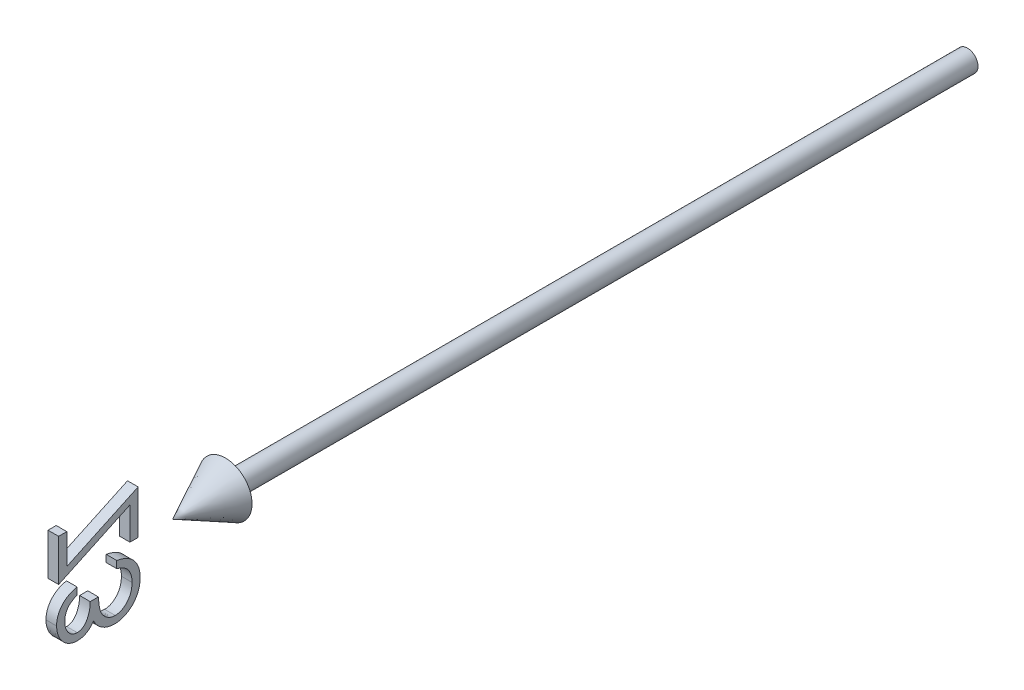
from build123d import *

# Parameters (mm, degrees)
BOSS_EXTRUDE1_DEPTH        = 1
BOSS_EXTRUDE1_DEPTH_BACK   = 1
BOSS_EXTRUDE1_2_DEPTH      = 1
BOSS_EXTRUDE1_2_DEPTH_BACK = 1


with BuildPart() as part:
    # Sketch2 → Revolve1 (revolve)
    with BuildSketch(Plane(origin=(0, 0, 0), x_dir=(1, 0, 0), z_dir=(0, 1, 0))):
        Polygon((0, -150), (5, -140), (2, -140), (2, 0), (0, 0), align=None)
    revolve(axis=Axis((0, 0, -41.949952025), (0, 0, 1)))


with BuildPart() as body_2:
    # Sketch3 → Boss-Extrude1 (new, two sides: drawn at the far end of the back side and taken through both)
    with BuildSketch(Plane(origin=(0, 0, 0), x_dir=(0, -1, 0), z_dir=(1, 0, 0)).offset(-BOSS_EXTRUDE1_DEPTH_BACK)):
        Polygon((-8.958586521, -170.961538462), (-8.958586521, -172.5), (-1.073971137, -172.5), (-7.366038444, -159.038461538), (-1.266278829, -159.038461538), (-1.266278829, -157.5), (-9.535509598, -157.5), (-3.243442291, -170.961538462), align=None)
    extrude(amount=BOSS_EXTRUDE1_DEPTH + BOSS_EXTRUDE1_DEPTH_BACK)


with BuildPart() as body_3:
    # Sketch3 → Boss-Extrude1 2 (new, two sides: drawn at the far end of the back side and taken through both)
    with BuildSketch(Plane(origin=(0, 0, 0), x_dir=(0, -1, 0), z_dir=(1, 0, 0)).offset(-BOSS_EXTRUDE1_2_DEPTH_BACK)):
        with BuildLine():
            Line((2.387567325, -169.038461538), (1.041413479, -169.038461538))
            add(Edge.make_bspline(
                [(1.041413479, -169.038461538), (1.077882982, -169.189457898), (1.149177877, -169.484643431), (1.297881763, -169.906388835), (1.459878571, -170.305489641), (1.654403305, -170.674472814), (1.86658368, -171.020753826), (2.109681058, -171.336478645), (2.372479869, -171.629677068), (2.663158223, -171.889876658), (2.967995345, -172.125495497), (3.291286572, -172.3263886), (3.626527545, -172.499206398), (3.976040972, -172.641578821), (4.340867422, -172.748831065), (4.717708665, -172.826645946), (5.107552237, -172.877179293), (5.372184768, -172.882111134), (5.506557709, -172.884615385)],
                knots=[0, 0, 0, 0, 1.162005537, 2.271625781, 3.343758855, 4.383309926, 5.390229558, 6.379919256, 7.361854164, 8.333198761, 9.295911338, 10.242430842, 11.177959212, 12.116337295, 13.062827104, 14.020064771, 14.994644689, 16, 16, 16, 16], degree=3))
            add(Edge.make_bspline(
                [(5.506557709, -172.884615385), (5.70234089, -172.878704398), (6.089636651, -172.86701136), (6.658621138, -172.760235204), (7.207307505, -172.591270351), (7.729689996, -172.35781152), (8.21491185, -172.069865892), (8.646638365, -171.727159877), (9.019017697, -171.336305728), (9.331422172, -170.904594738), (9.576029311, -170.443213983), (9.756399483, -169.968356167), (9.866206688, -169.481147718), (9.880437645, -169.15218795), (9.887567325, -168.987379808)],
                knots=[0, 0, 0, 0, 1.083050992, 2.142477498, 3.193116406, 4.255571735, 5.30263384, 6.308962982, 7.297363603, 8.282367274, 9.249857812, 10.179914175, 11.08814088, 12, 12, 12, 12], degree=3))
            add(Edge.make_bspline(
                [(9.887567325, -168.987379808), (9.882580506, -168.828779259), (9.872822076, -168.518422597), (9.789963337, -168.065330466), (9.650522211, -167.638295037), (9.457366086, -167.235518627), (9.20733087, -166.859555028), (8.904447884, -166.509558353), (8.546579333, -166.183976247), (8.275383884, -165.99746422), (8.13576444, -165.901442308)],
                knots=[0, 0, 0, 0, 1.024540389, 2.004866551, 2.965041327, 3.920577974, 4.882998113, 5.874504559, 6.905732034, 8, 8, 8, 8], degree=3))
            add(Edge.make_bspline(
                [(8.13576444, -165.901442308), (8.295532489, -165.824672319), (8.612592213, -165.672322261), (9.040398309, -165.368793148), (9.434677535, -165.026944029), (9.651975175, -164.757191084), (9.761365402, -164.621394231)],
                knots=[0, 0, 0, 0, 1.015663554, 2.015584519, 3.001021554, 4, 4, 4, 4], degree=3))
            add(Edge.make_bspline(
                [(9.761365402, -164.621394231), (9.833571964, -164.522585827), (9.976802655, -164.326587074), (10.153097142, -164.011277108), (10.314859216, -163.693516116), (10.43391142, -163.360810145), (10.536648754, -163.023846298), (10.604246499, -162.675408835), (10.647641548, -162.318808204), (10.653735099, -162.077450896), (10.656798094, -161.956129808)],
                knots=[0, 0, 0, 0, 1.02516404, 2.033540309, 3.025129118, 4.011046665, 4.991655828, 5.976607087, 6.982917762, 8, 8, 8, 8], degree=3))
            add(Edge.make_bspline(
                [(10.656798094, -161.956129808), (10.649089282, -161.746097574), (10.633707934, -161.327021522), (10.496818218, -160.707702714), (10.283287572, -160.103433888), (9.98569722, -159.522784723), (9.615837461, -158.981167895), (9.178243054, -158.495173184), (8.672448055, -158.081236409), (8.113179027, -157.732313488), (7.504922756, -157.455796007), (6.856929846, -157.256542751), (6.173036865, -157.137018745), (5.705353383, -157.122678096), (5.467495209, -157.115384615)],
                knots=[0, 0, 0, 0, 0.955619592, 1.906742024, 2.874954321, 3.868585453, 4.869520953, 5.854611167, 6.836527075, 7.836578462, 8.849204403, 9.870874567, 10.917152508, 12, 12, 12, 12], degree=3))
            add(Edge.make_bspline(
                [(5.467495209, -157.115384615), (5.307136874, -157.119137984), (4.991605144, -157.12652336), (4.527560673, -157.176112305), (4.085547169, -157.26914479), (3.661272508, -157.386146016), (3.261140023, -157.547913319), (2.879394184, -157.740769913), (2.517708313, -157.969661352), (2.178230348, -158.234972564), (1.861322974, -158.531948792), (1.575059945, -158.865523642), (1.316274062, -159.22947145), (1.086609618, -159.627065987), (0.885100046, -160.057193647), (0.716081847, -160.52157803), (0.568508081, -161.016619024), (0.4997621, -161.361508239), (0.464490402, -161.538461538)],
                knots=[0, 0, 0, 0, 1.048603596, 2.063302207, 3.045874044, 3.999447474, 4.937100059, 5.862643889, 6.7929026, 7.7308982, 8.676022965, 9.627908155, 10.600123445, 11.591992905, 12.626222643, 13.701663232, 14.820785756, 16, 16, 16, 16], degree=3))
            Line((0.464490402, -161.538461538), (1.810644248, -161.538461538))
            add(Edge.make_bspline(
                [(1.810644248, -161.538461538), (1.845715497, -161.422965767), (1.913932123, -161.19831646), (2.030050543, -160.875000865), (2.162343137, -160.578609208), (2.304262674, -160.306967257), (2.453313157, -160.057399817), (2.620091408, -159.836506093), (2.792244887, -159.634583798), (2.922013544, -159.520821175), (2.985524056, -159.465144231)],
                knots=[0, 0, 0, 0, 1.198163088, 2.33053128, 3.407730985, 4.417276592, 5.372219308, 6.28897303, 7.162600585, 8, 8, 8, 8], degree=3))
            add(Edge.make_bspline(
                [(2.985524056, -159.465144231), (3.069518764, -159.400420928), (3.237248909, -159.271174108), (3.510400544, -159.105766423), (3.79867748, -158.964181399), (4.104483743, -158.849095157), (4.427860356, -158.762707273), (4.767495568, -158.70052934), (5.123946634, -158.659482243), (5.367217522, -158.655752252), (5.491533671, -158.653846154)],
                knots=[0, 0, 0, 0, 0.946083416, 1.889246487, 2.84504177, 3.809995578, 4.801312957, 5.829064617, 6.89060985, 8, 8, 8, 8], degree=3))
            add(Edge.make_bspline(
                [(5.491533671, -158.653846154), (5.631907725, -158.656481455), (5.906397071, -158.661634559), (6.306891349, -158.709161849), (6.68801812, -158.7780779), (7.045887986, -158.885876004), (7.385370678, -159.015197637), (7.698887961, -159.18450339), (7.995656856, -159.375706866), (8.266983406, -159.598113283), (8.511597558, -159.838510547), (8.722971211, -160.093550619), (8.90604497, -160.355325599), (9.05320572, -160.629942168), (9.16961678, -160.914706557), (9.248816734, -161.210684643), (9.303898319, -161.515384104), (9.308383304, -161.722508678), (9.310644248, -161.826923077)],
                knots=[0, 0, 0, 0, 1.216990249, 2.379719373, 3.493992396, 4.571561497, 5.616923107, 6.638958652, 7.655775068, 8.674704564, 9.676001865, 10.625896028, 11.54399481, 12.441854662, 13.322657739, 14.20572845, 15.095482574, 16, 16, 16, 16], degree=3))
            add(Edge.make_bspline(
                [(9.310644248, -161.826923077), (9.304072128, -161.966677177), (9.290960591, -162.245489979), (9.191271648, -162.65583968), (9.025831107, -163.051362848), (8.798724763, -163.426879766), (8.51564065, -163.770839724), (8.189960141, -164.078720963), (7.814734235, -164.335079469), (7.467421351, -164.511707124), (7.158983186, -164.629387155), (6.895561346, -164.711908051), (6.600388976, -164.777872173), (6.277012802, -164.841679918), (5.924067986, -164.895172125), (5.541236851, -164.939973992), (5.128365289, -164.975766197), (4.842546582, -164.991758771), (4.695259633, -165)],
                knots=[0, 0, 0, 0, 1.070440979, 2.135555593, 3.216243406, 4.345886539, 5.486149072, 6.621334998, 7.769144672, 8.957074012, 9.598644492, 10.297969361, 11.070758978, 11.915404831, 12.824182859, 13.805940418, 14.869366021, 16, 16, 16, 16], degree=3))
            Line((4.695259633, -165), (4.695259633, -166.538461538))
            add(Edge.make_bspline(
                [(4.695259633, -166.538461538), (4.880763881, -166.542078261), (5.243994071, -166.549160054), (5.776072015, -166.617174729), (6.283308569, -166.727572157), (6.758074146, -166.881701308), (7.18856769, -167.069341367), (7.565618942, -167.279426553), (7.875663405, -167.521793169), (8.124254, -167.78498421), (8.308636345, -168.069055173), (8.444736501, -168.363785951), (8.525236874, -168.674659554), (8.536002291, -168.886772035), (8.541413479, -168.993389423)],
                knots=[0, 0, 0, 0, 1.321816535, 2.58820849, 3.816448615, 5.017641336, 6.139869627, 7.160068286, 8.085608132, 8.934319198, 9.728416342, 10.48890201, 11.240453369, 12, 12, 12, 12], degree=3))
            add(Edge.make_bspline(
                [(8.541413479, -168.993389423), (8.539676508, -169.071735839), (8.536220886, -169.227602318), (8.490900512, -169.456030872), (8.425944751, -169.677479423), (8.33157719, -169.889360491), (8.209531247, -170.092347627), (8.061873825, -170.287182207), (7.888230891, -170.475724728), (7.689730048, -170.653816891), (7.468198023, -170.814102991), (7.232526248, -170.956995816), (6.98179593, -171.077148339), (6.717641012, -171.176746622), (6.438633609, -171.251536628), (6.146241516, -171.305271612), (5.839863659, -171.338858792), (5.630842238, -171.343695244), (5.524586556, -171.346153846)],
                knots=[0, 0, 0, 0, 0.884246871, 1.759167212, 2.622361933, 3.489113179, 4.372562419, 5.294145153, 6.247651513, 7.265905295, 8.30305477, 9.334068495, 10.37719476, 11.441246459, 12.52060732, 13.637552802, 14.799054011, 16, 16, 16, 16], degree=3))
            add(Edge.make_bspline(
                [(5.524586556, -171.346153846), (5.353788049, -171.340202433), (5.02017884, -171.328577938), (4.539336404, -171.226403869), (4.092789714, -171.06451959), (3.752611213, -170.869044803), (3.500985165, -170.676749979), (3.317728145, -170.511318743), (3.141049606, -170.323753604), (2.977882574, -170.108909862), (2.818449734, -169.874175124), (2.664273432, -169.618256559), (2.520305814, -169.337505532), (2.432670368, -169.140073318), (2.387567325, -169.038461538)],
                knots=[0, 0, 0, 0, 1.4727372, 2.876598283, 4.222346151, 5.558423782, 6.24313385, 6.953189256, 7.68715613, 8.463578749, 9.278833271, 10.135787152, 11.040551781, 12, 12, 12, 12], degree=3))
        make_face()
    extrude(amount=BOSS_EXTRUDE1_2_DEPTH + BOSS_EXTRUDE1_2_DEPTH_BACK)


solid = Compound([part.part, body_2.part, body_3.part])
